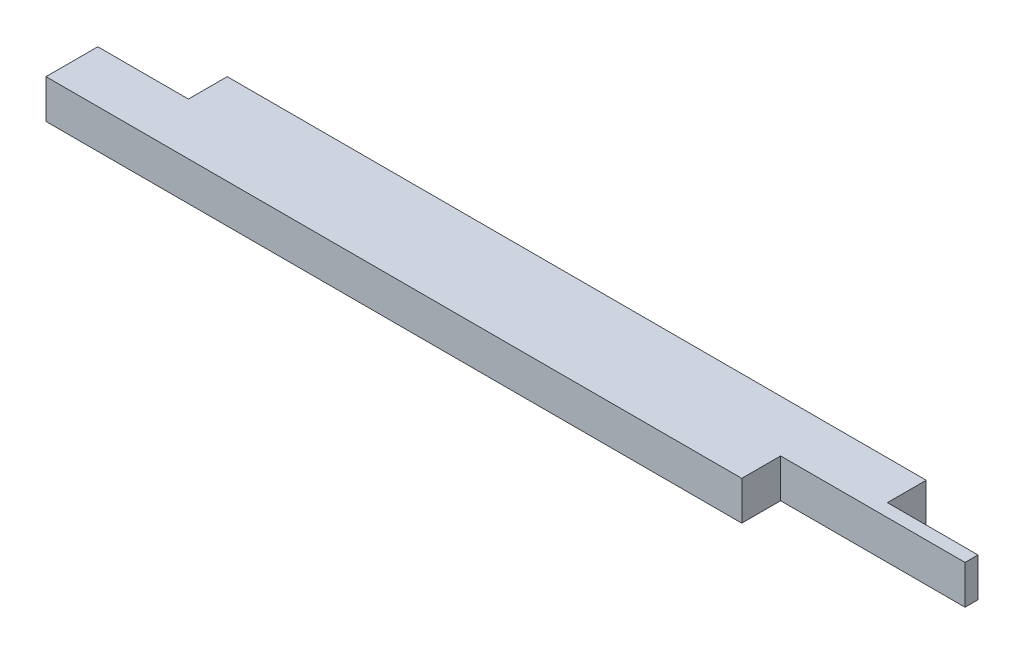
from build123d import *

# Parameters (mm, degrees)
SKETCH1_W           = 863.6
SKETCH1_H           = 88.9
BOSS_EXTRUDE1_DEPTH = 38.1
SKETCH3_W           = 88.9
SKETCH3_H           = 38.1
CUT_EXTRUDE1_DEPTH  = 39.1
SKETCH4_W           = 180.975
SKETCH4_H           = 38.1
CUT_EXTRUDE2_DEPTH  = 39.1


with BuildPart() as part:
    # Sketch1 → Boss-Extrude1 (new body)
    with BuildSketch(Plane(origin=(0, 0, 0), x_dir=(1, 0, 0), z_dir=(0, 1, 0))):
        with Locations((431.8, 44.45)):
            Rectangle(SKETCH1_W, SKETCH1_H)
    extrude(amount=BOSS_EXTRUDE1_DEPTH)

    # Sketch3 → Cut-Extrude1 (cut, through all)
    with BuildSketch(Plane(origin=(0, 38.1, 0), x_dir=(1, 0, 0), z_dir=(0, 1, 0))):
        with Locations((44.45, 69.85)):
            Rectangle(SKETCH3_W, SKETCH3_H)
        with Locations((819.15, 69.85)):
            Rectangle(SKETCH3_W, SKETCH3_H)
    extrude(amount=-CUT_EXTRUDE1_DEPTH, mode=Mode.SUBTRACT)

    # Sketch4 → Cut-Extrude2 (cut, through all)
    with BuildSketch(Plane(origin=(0, 38.1, 0), x_dir=(1, 0, 0), z_dir=(0, 1, 0))):
        with Locations((773.1125, 19.05)):
            Rectangle(SKETCH4_W, SKETCH4_H)
    extrude(amount=-CUT_EXTRUDE2_DEPTH, mode=Mode.SUBTRACT)


solid = part.part
